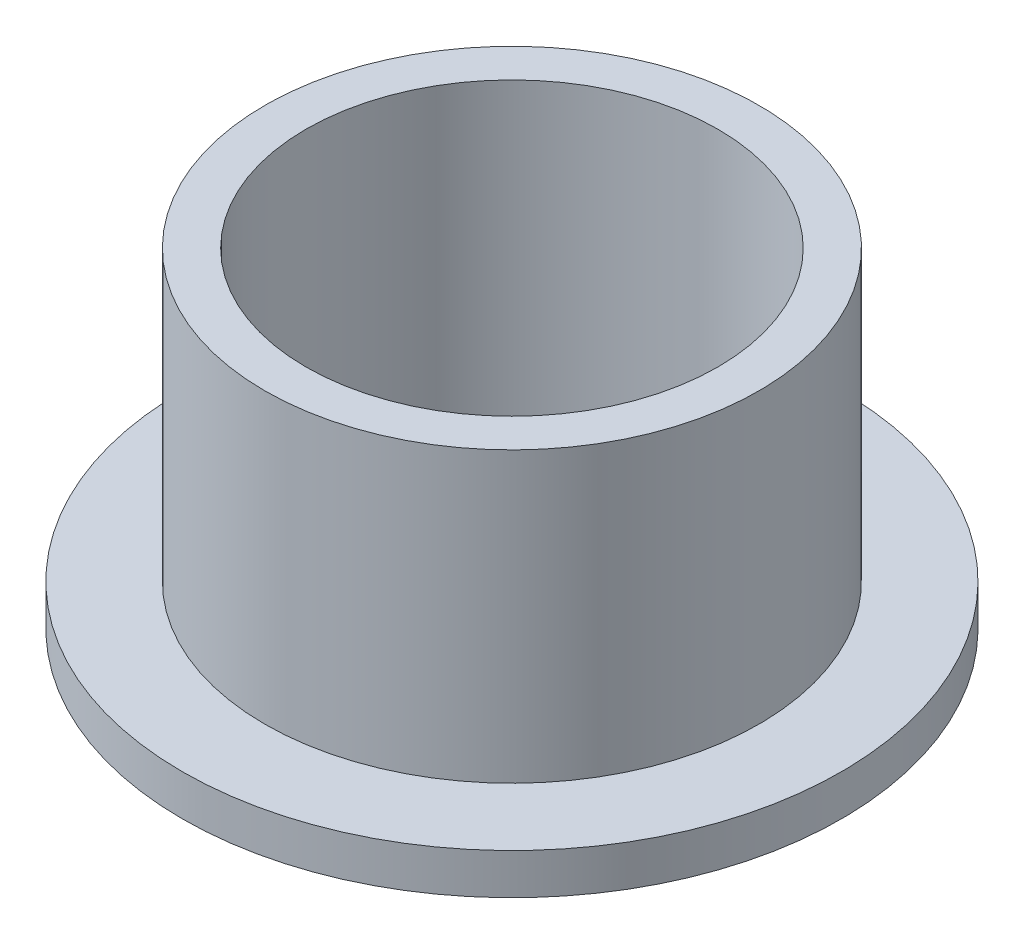
from build123d import *


with BuildPart() as part:
    # Sketch1 → Revolve1 (revolve)
    with BuildSketch(Plane.XY):
        Polygon((7.9375, 0), (12.7, 0), (12.7, 1.5748), (9.525, 1.5748), (9.525, 12.7), (7.9375, 12.7), align=None)
    revolve(axis=Axis((0, 26.712740385, 0), (0, -1, 0)))


solid = part.part
